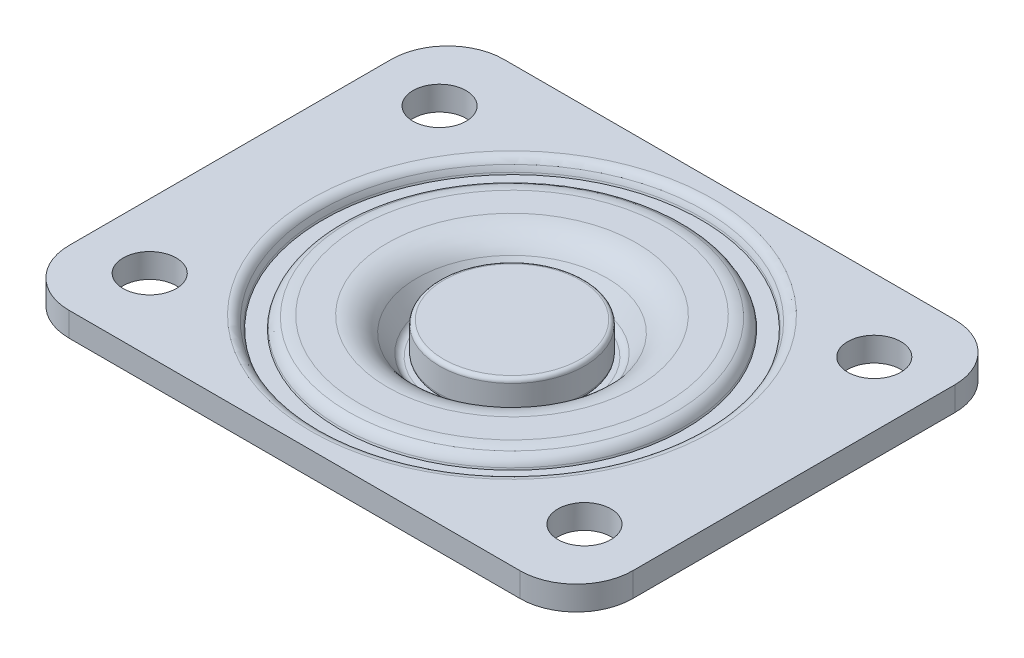
from build123d import *

# Parameters (mm, degrees)
SKETCH1_W           = 70
SKETCH1_H           = 54
BOSS_EXTRUDE1_DEPTH = 3
FILLET1_R           = 4
FILLET2_R           = 1.5
FILLET3_R           = 7
SKETCH6_R           = 3.3
CUT_EXTRUDE1_DEPTH  = 19.5
FILLET4_R           = 4.5
FILLET5_R           = 1
FILLET6_R           = 0.5


with BuildPart() as part:
    # Sketch1 → Boss-Extrude1 (new body)
    with BuildSketch(Plane(origin=(0, 0, 0), x_dir=(1, 0, 0), z_dir=(0, 1, 0))):
        Rectangle(SKETCH1_W, SKETCH1_H)
    extrude(amount=BOSS_EXTRUDE1_DEPTH)

    # Sketch2 → Revolve1 (revolve)
    with BuildSketch(Plane.XY):
        Polygon((-14.75, 0), (-11.599066078, -4.5), (-5, -4.5), (-5, -15.5), (0, -15.5), (0, 0), align=None)
    revolve(axis=Axis((0, -15.5, 0), (0, 1, 0)))

    # Fillet1
    fillet1_edges = [part.edges().sort_by_distance(p)[0] for p in [
        (11.599066078, -4.5, 0),
    ]]
    fillet(fillet1_edges, radius=FILLET1_R)

    # Fillet2
    fillet2_edges = [part.edges().sort_by_distance(p)[0] for p in [
        (14.75, 0, 0),
    ]]
    fillet(fillet2_edges, radius=FILLET2_R)

    # Fillet3
    fillet3_edges = [part.edges().sort_by_distance(p)[0] for p in [
        (35, 1.5, 27),
        (-35, 1.5, 27),
        (-35, 1.5, -27),
        (35, 1.5, -27),
    ]]
    fillet(fillet3_edges, radius=FILLET3_R)

    # Sketch3 → Revolve2 (revolve)
    with BuildSketch(Plane(origin=(0, 0, 0), x_dir=(0, 0, -1), z_dir=(1, 0, 0))):
        with BuildLine():
            Line((20.29, 0), (20.502160809, -0.367473301))
            ThreePointArc((20.502160809, -0.367473301), (22.52, -1.532473301), (24.537839191, -0.367473301))
            Line((24.537839191, -0.367473301), (24.75, 0))
            Line((24.75, 0), (20.29, 0))
        make_face()
    revolve(axis=Axis((0, 55, 0), (0, -1, 0)))

    # Sketch4 → Cut-Revolve1 (revolve, cut)
    with BuildSketch(Plane(origin=(0, 0, 0), x_dir=(0, 0, -1), z_dir=(1, 0, 0))):
        with BuildLine():
            Line((0, 3), (0, 2.5))
            Line((0, 2.5), (9, 2.5))
            Line((9, 2.5), (9, -1))
            ThreePointArc((9, -1), (8.853553391, -1.353553391), (8.5, -1.5))
            Line((8.5, -1.5), (9.999066078, -1.5))
            Line((9.999066078, -1.5), (13.15, 3))
            Line((13.15, 3), (0, 3))
        make_face()
    revolve(axis=Axis((0, 55, 0), (0, -1, 0)), mode=Mode.SUBTRACT)

    # Sketch5 → Cut-Revolve2 (revolve, cut)
    with BuildSketch(Plane(origin=(0, 0, 0), x_dir=(0, 0, -1), z_dir=(1, 0, 0))):
        with BuildLine():
            Line((21.413255939, 1.705375654), (21.488006564, 1.5))
            Line((21.488006564, 1.5), (23.488006564, 1.5))
            Line((23.488006564, 1.5), (23.562010813, 1.703325005))
            ThreePointArc((23.562010813, 1.703325005), (23.695887988, 2.028345161), (23.856350384, 2.34109589))
            ThreePointArc((23.856350384, 2.34109589), (24.332840552, 2.823259689), (24.987277463, 3))
            Line((24.987277463, 3), (18.999733381, 3))
            ThreePointArc((18.999733381, 3), (19.682644585, 2.941272927), (20.345503101, 2.766816143))
            ThreePointArc((20.345503101, 2.766816143), (20.997863005, 2.355284), (21.413255939, 1.705375654))
        make_face()
    revolve(axis=Axis((0, 55, 0), (0, -1, 0)), mode=Mode.SUBTRACT)

    # Sketch6 → Cut-Extrude1 (cut, through all)
    with BuildSketch(Plane(origin=(0, 3, 0), x_dir=(1, 0, 0), z_dir=(0, 1, 0))):
        with Locations((-27, 18)):
            Circle(SKETCH6_R)
        with Locations((27, 18)):
            Circle(SKETCH6_R)
        with Locations((27, -18)):
            Circle(SKETCH6_R)
        with Locations((-27, -18)):
            Circle(SKETCH6_R)
    extrude(amount=-CUT_EXTRUDE1_DEPTH, mode=Mode.SUBTRACT)

    # Fillet4
    fillet4_edges = [part.edges().sort_by_distance(p)[0] for p in [
        (0, 3, 13.15),
    ]]
    fillet(fillet4_edges, radius=FILLET4_R)

    # Fillet5
    fillet5_edges = [part.edges().sort_by_distance(p)[0] for p in [
        (0, -1.5, 9.999066078),
    ]]
    fillet(fillet5_edges, radius=FILLET5_R)

    # Fillet6
    fillet6_edges = [part.edges().sort_by_distance(p)[0] for p in [
        (0, 0, 24.75),
        (0, 0, 20.29),
        (0, 2.5, 9),
    ]]
    fillet(fillet6_edges, radius=FILLET6_R)


solid = part.part
